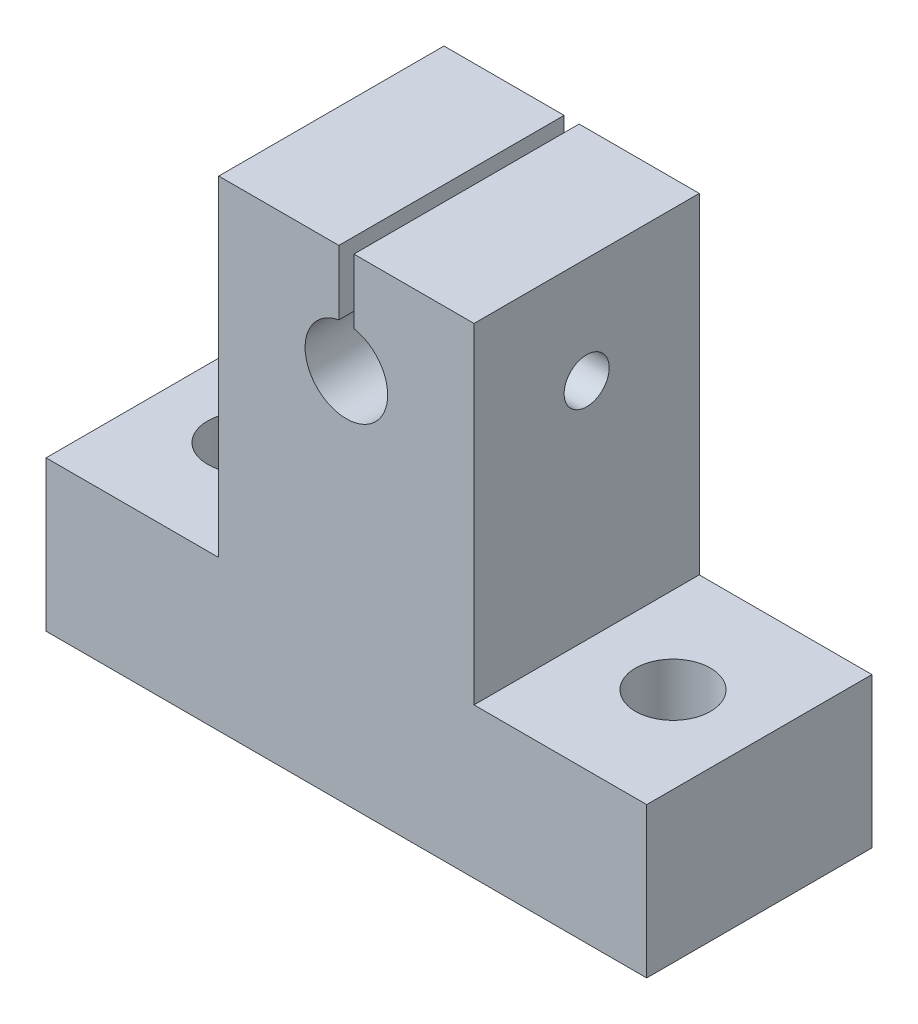
from build123d import *

# Parameters (mm, degrees)
CROQUIS1_W              = 17
CROQUIS1_H              = 15
SALIENTE_EXTRUIR1_DEPTH = 32
CROQUIS1_3_W            = 11.5
CROQUIS1_3_H            = 15
SALIENTE_EXTRUIR2_DEPTH = 10
CORTAR_EXTRUIR1_DEPTH   = 20
CROQUIS3_R              = 2.5
CORTAR_EXTRUIR2_DEPTH   = 20
CROQUIS4_R              = 1.5
CORTAR_EXTRUIR3_DEPTH   = 20


with BuildPart() as part:
    # Croquis1 → Saliente-Extruir1 (new body)
    with BuildSketch(Plane(origin=(0, 0, 0), x_dir=(1, 0, 0), z_dir=(0, 1, 0))):
        Rectangle(CROQUIS1_W, CROQUIS1_H)
    extrude(amount=SALIENTE_EXTRUIR1_DEPTH)

    # Croquis1_3 → Saliente-Extruir2 (add)
    with BuildSketch(Plane(origin=(0, 0, 0), x_dir=(1, 0, 0), z_dir=(0, 1, 0))):
        with Locations((-14.25, 0)):
            Rectangle(CROQUIS1_3_W, CROQUIS1_3_H)
        with Locations((14.25, 0)):
            Rectangle(CROQUIS1_3_W, CROQUIS1_3_H)
    extrude(amount=SALIENTE_EXTRUIR2_DEPTH)

    # Croquis2 → Cortar-Extruir1 (cut)
    with BuildSketch(Plane(origin=(0, 0, -7.5), x_dir=(-1, 0, 0), z_dir=(0, 0, -1))):
        with BuildLine():
            Line((0.5, 32), (-0.5, 32))
            Line((-0.5, 32), (-0.5, 27.704163457))
            ThreePointArc((-0.5, 27.704163457), (0, 22.25), (0.5, 27.704163457))
            Line((0.5, 27.704163457), (0.5, 32))
        make_face()
    extrude(amount=-CORTAR_EXTRUIR1_DEPTH, mode=Mode.SUBTRACT)

    # Croquis3 → Cortar-Extruir2 (cut)
    with BuildSketch(Plane(origin=(0, 10, 0), x_dir=(1, 0, 0), z_dir=(0, 1, 0))):
        with Locations((14.25, 0)):
            Circle(CROQUIS3_R)
        with Locations((-14.25, 0)):
            Circle(CROQUIS3_R)
    extrude(amount=-CORTAR_EXTRUIR2_DEPTH, mode=Mode.SUBTRACT)

    # Croquis4 → Cortar-Extruir3 (cut)
    with BuildSketch(Plane.ZY.offset(8.5)):
        with Locations((0, 24.943618043)):
            Circle(CROQUIS4_R)
    extrude(amount=-CORTAR_EXTRUIR3_DEPTH, mode=Mode.SUBTRACT)


solid = part.part
